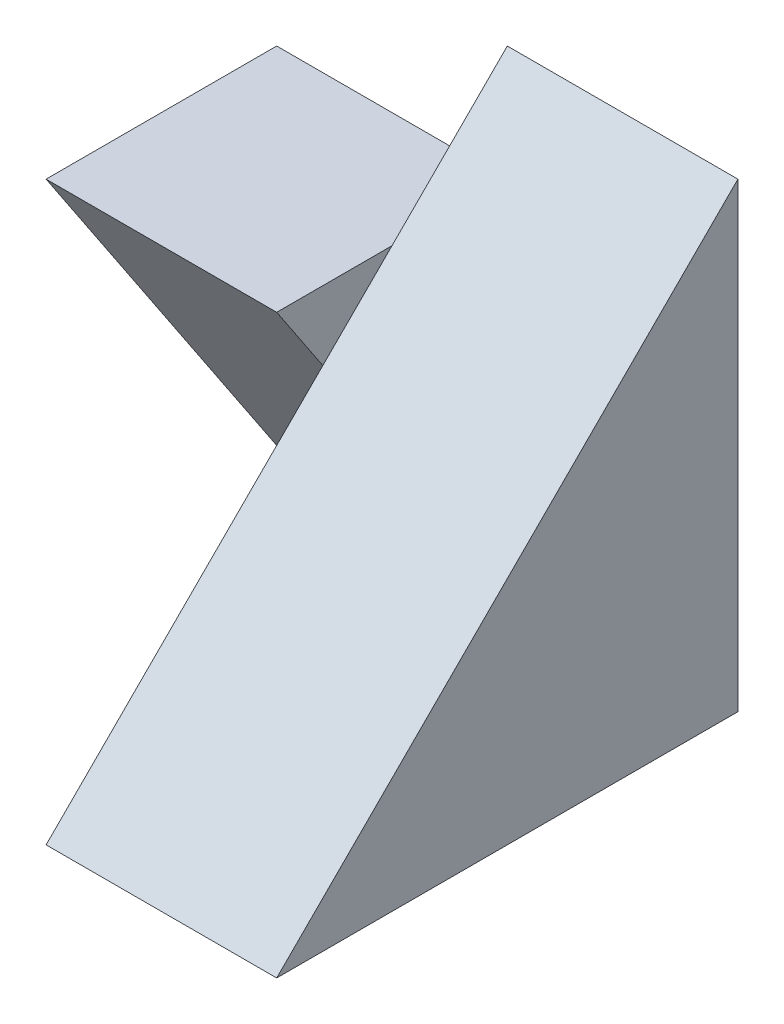
from build123d import *

# Parameters (mm, degrees)
SKETCH1_W           = 4
SKETCH1_H           = 4
BOSS_EXTRUDE1_DEPTH = 2
SKETCH2_W           = 2
SKETCH2_H           = 3
BOSS_EXTRUDE2_DEPTH = 2
CUT_EXTRUDE1_DEPTH  = 2
CUT_EXTRUDE2_DEPTH  = 2


with BuildPart() as part:
    # Sketch1 → Boss-Extrude1 (new body)
    with BuildSketch(Plane(origin=(0, 0, 0), x_dir=(0, 0, -1), z_dir=(1, 0, 0))):
        with Locations((2, 2)):
            Rectangle(SKETCH1_W, SKETCH1_H)
    extrude(amount=BOSS_EXTRUDE1_DEPTH)

    # Sketch2 → Boss-Extrude2 (add)
    with BuildSketch(Plane.ZY):
        with Locations((-3, 1.5)):
            Rectangle(SKETCH2_W, SKETCH2_H)
    extrude(amount=BOSS_EXTRUDE2_DEPTH)

    # Sketch3 → Cut-Extrude1 (cut)
    with BuildSketch(Plane.ZY.offset(2)):
        Polygon((-2, 3), (-4, 0), (-2, 0), align=None)
    extrude(amount=-CUT_EXTRUDE1_DEPTH, mode=Mode.SUBTRACT)

    # Sketch4 → Cut-Extrude2 (cut)
    with BuildSketch(Plane(origin=(2, 0, 0), x_dir=(0, 0, -1), z_dir=(1, 0, 0))):
        Polygon((4, 4), (0, 0), (0, 4), align=None)
    extrude(amount=-CUT_EXTRUDE2_DEPTH, mode=Mode.SUBTRACT)


solid = part.part
